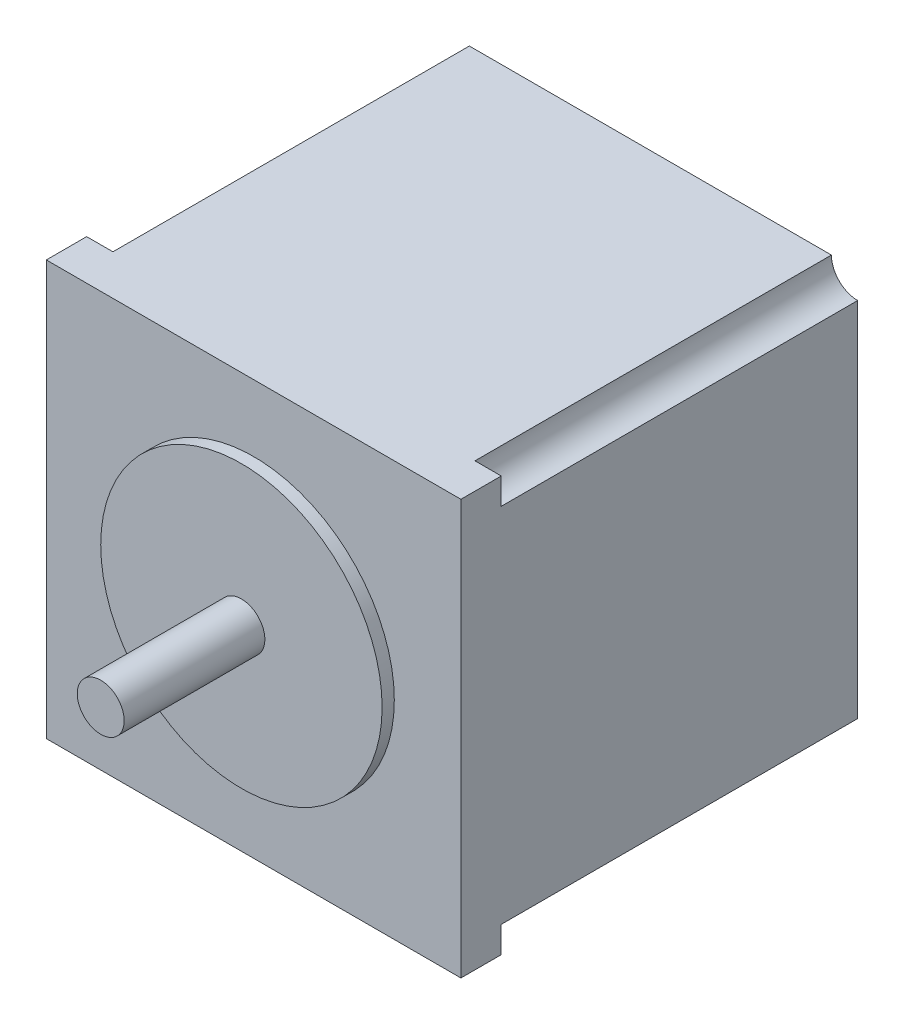
from build123d import *

# Parameters (mm, degrees)
SKETCH2_W           = 56.134
SKETCH2_H           = 56.134
BOSS_EXTRUDE1_DEPTH = 5.461
SKETCH3_R           = 19.05
BOSS_EXTRUDE2_DEPTH = 1.651
BOSS_EXTRUDE3_DEPTH = 48.26
SKETCH5_R           = 3.175
BOSS_EXTRUDE4_DEPTH = 19.05


with BuildPart() as part:
    # Sketch2 → Boss-Extrude1 (new body)
    with BuildSketch(Plane.XY):
        with Locations((28.067, 28.067)):
            Rectangle(SKETCH2_W, SKETCH2_H)
    extrude(amount=BOSS_EXTRUDE1_DEPTH)

    # Sketch3 → Boss-Extrude2 (add)
    with BuildSketch(Plane.XY.offset(5.461)):
        with Locations((28.067, 28.067)):
            Circle(SKETCH3_R)
    extrude(amount=BOSS_EXTRUDE2_DEPTH)

    # Sketch4 → Boss-Extrude3 (add)
    with BuildSketch(Plane(origin=(0, 0, 0), x_dir=(-1, 0, 0), z_dir=(0, 0, -1))):
        with BuildLine():
            Line((-52.578, 56.134), (-3.556, 56.134))
            ThreePointArc((-3.556, 56.134), (-2.514471714, 53.619528286), (0, 52.578))
            Line((0, 52.578), (0, 3.556))
            ThreePointArc((0, 3.556), (-2.514471714, 2.514471714), (-3.556, 0))
            Line((-3.556, 0), (-52.578, 0))
            ThreePointArc((-52.578, 0), (-53.619528286, 2.514471714), (-56.134, 3.556))
            Line((-56.134, 3.556), (-56.134, 52.578))
            ThreePointArc((-56.134, 52.578), (-53.619528286, 53.619528286), (-52.578, 56.134))
        make_face()
    extrude(amount=BOSS_EXTRUDE3_DEPTH)

    # Sketch5 → Boss-Extrude4 (add)
    with BuildSketch(Plane.XY.offset(7.112)):
        with Locations((28.067, 28.067)):
            Circle(SKETCH5_R)
    extrude(amount=BOSS_EXTRUDE4_DEPTH)


solid = part.part
